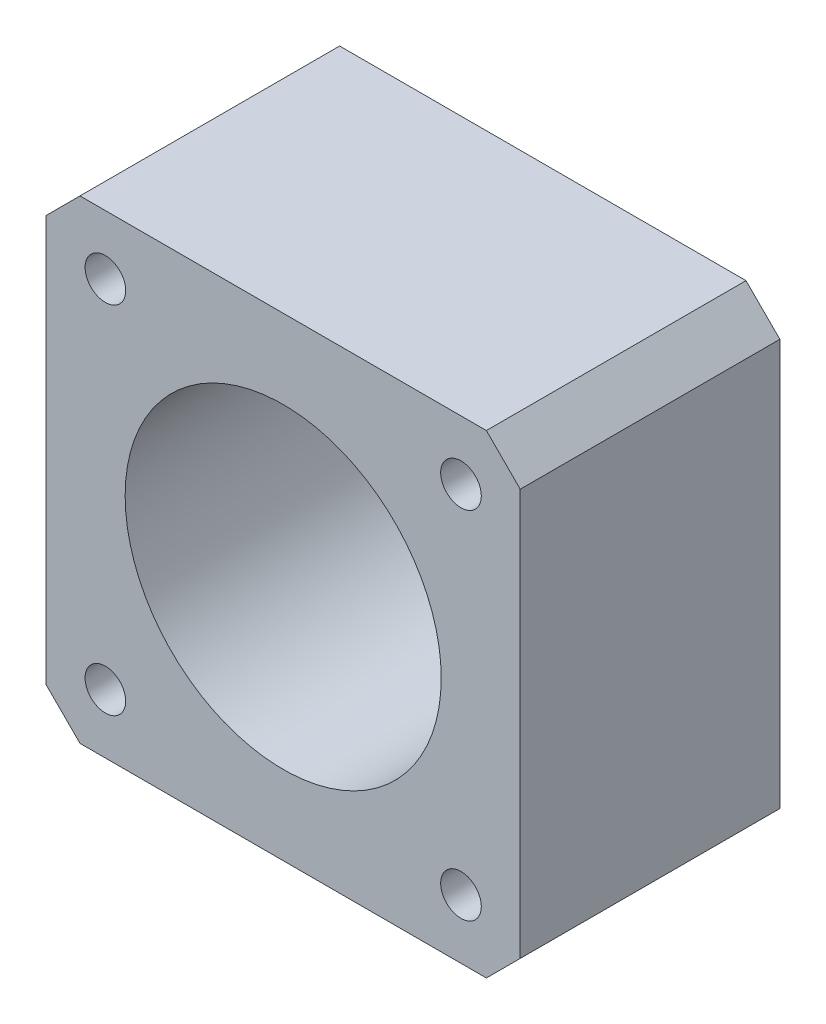
from build123d import *

# Parameters (mm, degrees)
SKETCH1_W           = 42
SKETCH1_H           = 42
BOSS_EXTRUDE1_DEPTH = 23
CHAMFER1_SIZE       = 3
CUT_EXTRUDE_2_REACH = 25
SKETCH4_R           = 1.8
CUT_EXTRUDE_3_REACH = 25
SKETCH2_R           = 14


with BuildPart() as part:
    # Sketch1 → Boss-Extrude1 (new body)
    with BuildSketch(Plane.XY):
        Rectangle(SKETCH1_W, SKETCH1_H)
    extrude(amount=BOSS_EXTRUDE1_DEPTH)

    # Chamfer1
    chamfer1_edges = [part.edges().sort_by_distance(p)[0] for p in [
        (21, -21, 11.5),
        (-21, -21, 11.5),
        (-21, 21, 11.5),
        (21, 21, 11.5),
    ]]
    chamfer(chamfer1_edges, length=CHAMFER1_SIZE)

    # Sketch4 → Вырез-Вытянуть2 (cut, up to next)
    with BuildSketch(Plane.XY.offset(23), mode=Mode.PRIVATE) as cut_extrude_2_sk1:
        with Locations((-15.75, 15.75)):
            Circle(SKETCH4_R)
    cut_extrude_2_tool1 = extrude(cut_extrude_2_sk1.sketch, amount=-CUT_EXTRUDE_2_REACH, mode=Mode.PRIVATE) & part.part
    add(cut_extrude_2_tool1.solids().sort_by_distance((-15.75, 15.75, 23))[0], mode=Mode.SUBTRACT)
    # Sketch4 → Вырез-Вытянуть2 (cut, up to next)
    with BuildSketch(Plane.XY.offset(23), mode=Mode.PRIVATE) as cut_extrude_2_sk2:
        with Locations((15.75, 15.75)):
            Circle(SKETCH4_R)
    cut_extrude_2_tool2 = extrude(cut_extrude_2_sk2.sketch, amount=-CUT_EXTRUDE_2_REACH, mode=Mode.PRIVATE) & part.part
    add(cut_extrude_2_tool2.solids().sort_by_distance((15.75, 15.75, 23))[0], mode=Mode.SUBTRACT)
    # Sketch4 → Вырез-Вытянуть2 (cut, up to next)
    with BuildSketch(Plane.XY.offset(23), mode=Mode.PRIVATE) as cut_extrude_2_sk3:
        with Locations((-15.75, -15.75)):
            Circle(SKETCH4_R)
    cut_extrude_2_tool3 = extrude(cut_extrude_2_sk3.sketch, amount=-CUT_EXTRUDE_2_REACH, mode=Mode.PRIVATE) & part.part
    add(cut_extrude_2_tool3.solids().sort_by_distance((-15.75, -15.75, 23))[0], mode=Mode.SUBTRACT)
    # Sketch4 → Вырез-Вытянуть2 (cut, up to next)
    with BuildSketch(Plane.XY.offset(23), mode=Mode.PRIVATE) as cut_extrude_2_sk4:
        with Locations((15.75, -15.75)):
            Circle(SKETCH4_R)
    cut_extrude_2_tool4 = extrude(cut_extrude_2_sk4.sketch, amount=-CUT_EXTRUDE_2_REACH, mode=Mode.PRIVATE) & part.part
    add(cut_extrude_2_tool4.solids().sort_by_distance((15.75, -15.75, 23))[0], mode=Mode.SUBTRACT)

    # Sketch2 → Вырез-Вытянуть3 (cut, up to next)
    with BuildSketch(Plane.XY.offset(23), mode=Mode.PRIVATE) as cut_extrude_3_sk1:
        Circle(SKETCH2_R)
    cut_extrude_3_tool1 = extrude(cut_extrude_3_sk1.sketch, amount=-CUT_EXTRUDE_3_REACH, mode=Mode.PRIVATE) & part.part
    add(cut_extrude_3_tool1.solids().sort_by_distance((0, 0, 23))[0], mode=Mode.SUBTRACT)


solid = part.part
